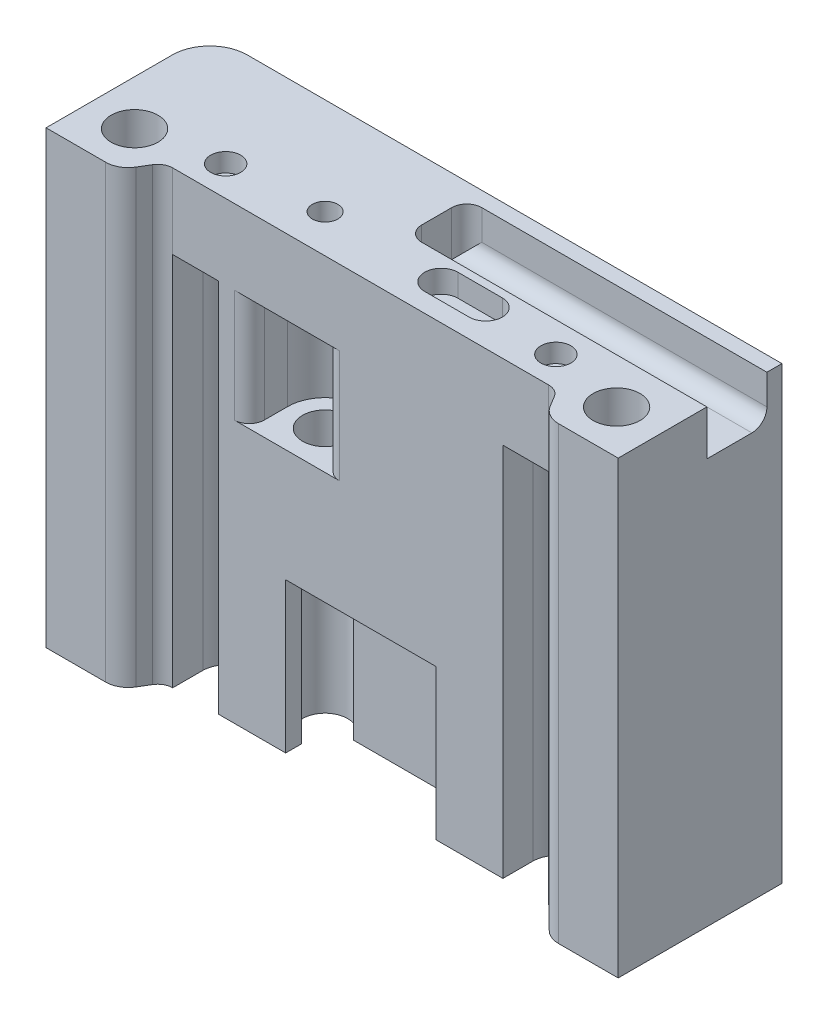
from build123d import *

# Parameters (mm, degrees)
SKETCH1_R           = 2
SKETCH1_R_2         = 3.125
SKETCH1_R_3         = 1.7
BOSS_EXTRUDE1_DEPTH = 10
FILLET2_R           = 3
FILLET1_R           = 2
SKETCH1_4_R         = 3.125
CUT_EXTRUDE3_DEPTH  = 5.07
SKETCH1_7_R         = 1.7
CUT_EXTRUDE6_DEPTH  = 10
CUT_EXTRUDE5_DEPTH  = 3
SKETCH1_5_R         = 2
CUT_EXTRUDE4_DEPTH  = 2.48
SKETCH4_R           = 1.5
CUT_EXTRUDE7_DEPTH  = 10
SKETCH5_R           = 2.725
CUT_EXTRUDE8_DEPTH  = 2.8
BOSS_EXTRUDE2_DEPTH = 10
BOSS_EXTRUDE3_DEPTH = 50
FILLET13_R          = 5
CUT_EXTRUDE14_DEPTH = 15
SKETCH10_W          = 8
SKETCH10_H          = 6
CUT_EXTRUDE12_DEPTH = 40
FILLET12_R          = 2
FILLET14_R          = 2
CUT_EXTRUDE17_DEPTH = 20
SKETCH19_R          = 1.5
CUT_EXTRUDE18_DEPTH = 4
CUT_EXTRUDE19_START = 35
SKETCH20_R          = 3
CUT_EXTRUDE19_DEPTH = 109.331401869


with BuildPart() as part:
    # Sketch1 → Boss-Extrude1 (new body)
    with BuildSketch(Plane(origin=(0, 0, 0), x_dir=(1, 0, 0), z_dir=(0, 1, 0))):
        with BuildLine():
            ThreePointArc((-11.409245094, 8.977987014), (-9.849239736, 9.28), (-8.289234378, 8.977987014))
            ThreePointArc((-8.289234378, 8.977987014), (-5.835653376, 8.254222737), (-3.289234378, 8.01))
            Line((-3.289234378, 8.01), (38.12, 8.01))
            Line((38.12, 8.01), (38.12, -3.81))
            Line((38.12, -3.81), (28.478275237, -3.81))
            Line((28.478275237, -3.81), (26.178275237, 0))
            Line((26.178275237, 0), (-26.178275237, 0))
            Line((-26.178275237, 0), (-28.478275237, -3.81))
            Line((-28.478275237, -3.81), (-38.12, -3.81))
            Line((-38.12, -3.81), (-38.12, 8.01))
            Line((-38.12, 8.01), (-16.409245094, 8.01))
            ThreePointArc((-16.409245094, 8.01), (-13.862826096, 8.254222737), (-11.409245094, 8.977987014))
        make_face()
        with Locations((22, 4.005)):
            Circle(SKETCH1_R, mode=Mode.SUBTRACT)
        with Locations((-22, 4.005)):
            Circle(SKETCH1_R, mode=Mode.SUBTRACT)
        with Locations((-32.12, 1.98)):
            Circle(SKETCH1_R_2, mode=Mode.SUBTRACT)
        with Locations((32.12, 1.98)):
            Circle(SKETCH1_R_2, mode=Mode.SUBTRACT)
        with Locations((-9.849239736, 5.1)):
            Circle(SKETCH1_R_3, mode=Mode.SUBTRACT)
        with BuildLine():
            ThreePointArc((11.912105026, 2.53), (14.127105026, 4.745), (11.912105026, 6.96))
            Line((11.912105026, 6.96), (5.992105026, 6.96))
            ThreePointArc((5.992105026, 6.96), (3.777105026, 4.745), (5.992105026, 2.53))
            Line((5.992105026, 2.53), (11.912105026, 2.53))
        make_face(mode=Mode.SUBTRACT)
        with Locations((-22, 4.005)):
            Circle(SKETCH1_R)
        with Locations((-9.849239736, 5.1)):
            Circle(SKETCH1_R_3)
        with Locations((-32.12, 1.98)):
            Circle(SKETCH1_R_2)
        with BuildLine():
            Line((5.992105026, 2.53), (11.912105026, 2.53))
            ThreePointArc((11.912105026, 2.53), (14.127105026, 4.745), (11.912105026, 6.96))
            Line((11.912105026, 6.96), (5.992105026, 6.96))
            ThreePointArc((5.992105026, 6.96), (3.777105026, 4.745), (5.992105026, 2.53))
        make_face()
        with Locations((22, 4.005)):
            Circle(SKETCH1_R)
        with Locations((32.12, 1.98)):
            Circle(SKETCH1_R_2)
    extrude(amount=-BOSS_EXTRUDE1_DEPTH)

    # Fillet2
    fillet2_edges = [part.edges().sort_by_distance(p)[0] for p in [
        (28.478275237, -5, 3.81),
        (-28.478275237, -5, 3.81),
    ]]
    fillet(fillet2_edges, radius=FILLET2_R)

    # Fillet1
    fillet1_edges = [part.edges().sort_by_distance(p)[0] for p in [
        (26.178275237, -5, 0),
        (-26.178275237, -5, 0),
    ]]
    fillet(fillet1_edges, radius=FILLET1_R)

    # Sketch1_4 → Cut-Extrude3 (cut)
    with BuildSketch(Plane(origin=(0, 0, 0), x_dir=(1, 0, 0), z_dir=(0, 1, 0))):
        with Locations(Location((32.12, 1.98, 0), (0, 0, 270))):
            Circle(SKETCH1_4_R)
        with Locations(Location((-32.12, 1.98, 0), (0, 0, 270))):
            Circle(SKETCH1_4_R)
    extrude(amount=-CUT_EXTRUDE3_DEPTH, mode=Mode.SUBTRACT)

    # Sketch1_7 → Cut-Extrude6 (cut)
    with BuildSketch(Plane(origin=(0, 0, 0), x_dir=(1, 0, 0), z_dir=(0, 1, 0))):
        with Locations(Location((-9.849239736, 5.1, 0), (0, 0, 270))):
            Circle(SKETCH1_7_R)
    extrude(amount=-CUT_EXTRUDE6_DEPTH, mode=Mode.SUBTRACT)

    # Sketch1_6 → Cut-Extrude5 (cut)
    with BuildSketch(Plane(origin=(0, 0, 0), x_dir=(1, 0, 0), z_dir=(0, 1, 0))):
        with BuildLine():
            Line((5.992105026, 2.53), (11.912105026, 2.53))
            ThreePointArc((11.912105026, 2.53), (14.127105026, 4.745), (11.912105026, 6.96))
            Line((11.912105026, 6.96), (5.992105026, 6.96))
            ThreePointArc((5.992105026, 6.96), (3.777105026, 4.745), (5.992105026, 2.53))
        make_face()
    extrude(amount=-CUT_EXTRUDE5_DEPTH, mode=Mode.SUBTRACT)

    # Sketch1_5 → Cut-Extrude4 (cut)
    with BuildSketch(Plane(origin=(0, 0, 0), x_dir=(1, 0, 0), z_dir=(0, 1, 0))):
        with Locations(Location((-22, 4.005, 0), (0, 0, 270))):
            Circle(SKETCH1_5_R)
        with Locations(Location((22, 4.005, 0), (0, 0, 270))):
            Circle(SKETCH1_5_R)
    extrude(amount=-CUT_EXTRUDE4_DEPTH, mode=Mode.SUBTRACT)

    # Sketch4 → Cut-Extrude7 (cut)
    with BuildSketch(Plane(origin=(0, 0, 0), x_dir=(1, 0, 0), z_dir=(0, 1, 0))):
        with Locations(Location((-22, 4.005, 0), (0, 0, 270))):
            Circle(SKETCH4_R)
        with Locations(Location((22, 4.005, 0), (0, 0, 270))):
            Circle(SKETCH4_R)
    extrude(amount=-CUT_EXTRUDE7_DEPTH, mode=Mode.SUBTRACT)

    # Sketch5 → Cut-Extrude8 (cut)
    with BuildSketch(Plane.XZ.offset(10)):
        with Locations(Location((22, -4.005, 0), (0, 0, 270))):
            Circle(SKETCH5_R)
        with Locations(Location((-22, -4.005, 0), (0, 0, 90))):
            Circle(SKETCH5_R)
    extrude(amount=-CUT_EXTRUDE8_DEPTH, mode=Mode.SUBTRACT)

    # Sketch6 → Boss-Extrude2 (add)
    with BuildSketch(Plane(origin=(0, 0, 0), x_dir=(1, 0, 0), z_dir=(0, 1, 0))):
        with BuildLine():
            Line((-38.12, 8.01), (-38.12, 18.01))
            Line((-38.12, 18.01), (38.12, 18.01))
            Line((38.12, 18.01), (38.12, 8.01))
            Line((38.12, 8.01), (-3.289234378, 8.01))
            ThreePointArc((-3.289234378, 8.01), (-5.835653376, 8.254222737), (-8.289234378, 8.977987014))
            ThreePointArc((-8.289234378, 8.977987014), (-9.849239736, 9.28), (-11.409245094, 8.977987014))
            ThreePointArc((-11.409245094, 8.977987014), (-13.862826096, 8.254222737), (-16.409245094, 8.01))
            Line((-16.409245094, 8.01), (-38.12, 8.01))
        make_face()
    extrude(amount=-BOSS_EXTRUDE2_DEPTH)

    # Sketch8 → Boss-Extrude3 (add)
    with BuildSketch(Plane.XZ.offset(10)):
        with BuildLine():
            Line((18.950546011, 0), (-18.950546011, 0))
            Line((-18.950546011, 0), (-18.950546011, -4.005))
            ThreePointArc((-18.950546011, -4.005), (-22, -7.054453989), (-25.049453989, -4.005))
            Line((-25.049453989, -4.005), (-25.049453989, 0))
            ThreePointArc((-25.049453989, 0), (-26.032503369, 0.25827272), (-26.761657912, 0.966386084))
            Line((-26.761657912, 0.966386084), (-27.603201224, 2.360420875))
            ThreePointArc((-27.603201224, 2.360420875), (-28.696933037, 3.422590919), (-30.171507108, 3.81))
            Line((-30.171507108, 3.81), (-38.12, 3.81))
            Line((-38.12, 3.81), (-38.12, -18.01))
            Line((-38.12, -18.01), (38.12, -18.01))
            Line((38.12, -18.01), (38.12, 3.81))
            Line((38.12, 3.81), (30.171507108, 3.81))
            ThreePointArc((30.171507108, 3.81), (28.696933037, 3.422590919), (27.603201224, 2.360420875))
            Line((27.603201224, 2.360420875), (26.761657912, 0.966386084))
            ThreePointArc((26.761657912, 0.966386084), (26.032503369, 0.25827272), (25.049453989, 0))
            Line((25.049453989, 0), (25.049453989, -4.005))
            ThreePointArc((25.049453989, -4.005), (22, -7.054453989), (18.950546011, -4.005))
            Line((18.950546011, -4.005), (18.950546011, 0))
        make_face()
    extrude(amount=BOSS_EXTRUDE3_DEPTH)

    # Fillet13
    fillet13_edges = [part.edges().sort_by_distance(p)[0] for p in [
        (-38.12, -30, -18.01),
    ]]
    fillet(fillet13_edges, radius=FILLET13_R)

    # Sketch8_3 → Cut-Extrude14 (cut)
    with BuildSketch(Plane.XZ.offset(10)):
        with BuildLine():
            Line((-4.849239736, 0), (-4.849239736, -5.1))
            ThreePointArc((-4.849239736, -5.1), (-9.849239736, -10.1), (-14.849239736, -5.1))
            Line((-14.849239736, -5.1), (-14.849239736, 0))
            Line((-14.849239736, 0), (-4.849239736, 0))
        make_face()
    extrude(amount=CUT_EXTRUDE14_DEPTH, mode=Mode.SUBTRACT)

    # Sketch10 → Cut-Extrude12 (cut)
    with BuildSketch(Plane(origin=(38.12, 0, 0), x_dir=(0, 0, -1), z_dir=(1, 0, 0))):
        with Locations((12.01, -3)):
            Rectangle(SKETCH10_W, SKETCH10_H)
    extrude(amount=-CUT_EXTRUDE12_DEPTH, mode=Mode.SUBTRACT)

    # Fillet12
    fillet12_edges = [part.edges().sort_by_distance(p)[0] for p in [
        (-4.849239736, -17.5, 0),
        (-14.849239736, -17.5, 0),
    ]]
    fillet(fillet12_edges, radius=FILLET12_R)

    # Fillet14
    fillet14_edges = [part.edges().sort_by_distance(p)[0] for p in [
        (-1.88, -3, -16.01),
        (18.12, -6, -16.01),
        (-1.88, -3, -8.01),
    ]]
    fillet(fillet14_edges, radius=FILLET14_R)

    # Sketch18 → Cut-Extrude17 (cut)
    with BuildSketch(Plane.XZ.offset(60)):
        Polygon((-10, 0), (-10, -3), (-12.5, -3), (-12.5, -6), (12.5, -6), (12.5, -3), (10, -3), (10, 0), align=None)
    extrude(amount=-CUT_EXTRUDE17_DEPTH, mode=Mode.SUBTRACT)

    # Sketch19 → Cut-Extrude18 (cut)
    with BuildSketch(Plane.XY.offset(-6)):
        with Locations((0, -44)):
            Circle(SKETCH19_R)
    extrude(amount=-CUT_EXTRUDE18_DEPTH, mode=Mode.SUBTRACT)

    # Sketch20 → Cut-Extrude19 (cut, through all)
    with BuildSketch(Plane(origin=(0, -60, 0), x_dir=(1, 0, 0), z_dir=(0, 1, 0)).offset(CUT_EXTRUDE19_START)):
        with Locations(Location((-9.849239736, 5.1, 0), (0, 0, 267.119477763))):
            Circle(SKETCH20_R)
    extrude(amount=-CUT_EXTRUDE19_DEPTH, mode=Mode.SUBTRACT)


solid = part.part
